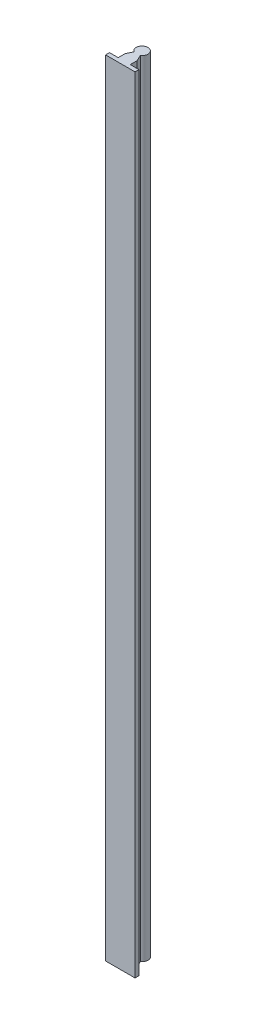
from build123d import *

# Parameters (mm, degrees)
BOSS_EXTRUDE1_DEPTH = 800


with BuildPart() as part:
    # Sketch1 → Boss-Extrude1 (new body)
    with BuildSketch(Plane(origin=(0, 0, 0), x_dir=(1, 0, 0), z_dir=(0, 1, 0))):
        with BuildLine():
            Line((-3.25, -5.04356025), (-6.15, -11.2))
            Line((-6.15, -11.2), (-6.15, -18.2))
            Line((-6.15, -18.2), (-15, -18.2))
            Line((-15, -18.2), (-15, -22.2))
            Line((-15, -22.2), (15, -22.2))
            Line((15, -22.2), (15, -18.2))
            Line((15, -18.2), (6.15, -18.2))
            Line((6.15, -18.2), (6.15, -11.2))
            Line((6.15, -11.2), (3.25, -5.04356025))
            ThreePointArc((3.25, -5.04356025), (0, 6), (-3.25, -5.04356025))
        make_face()
    extrude(amount=BOSS_EXTRUDE1_DEPTH)


solid = part.part
